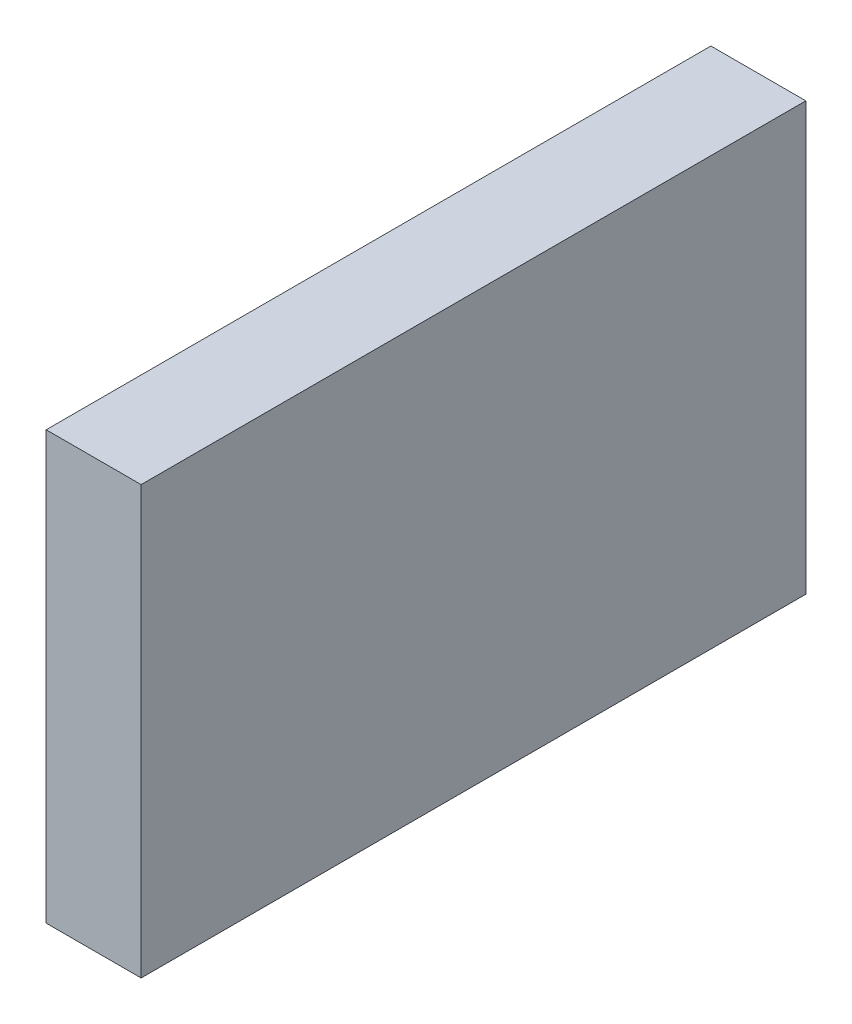
from build123d import *

# Parameters (mm, degrees)
SKETCH1_W           = 7
SKETCH1_H           = 4.5
BOSS_EXTRUDE1_DEPTH = 1


with BuildPart() as part:
    # Sketch1 → Boss-Extrude1 (new body)
    with BuildSketch(Plane(origin=(0, 0, 0), x_dir=(0, 0, -1), z_dir=(1, 0, 0))):
        with Locations((0.481339774, -0.318319493)):
            Rectangle(SKETCH1_W, SKETCH1_H)
    extrude(amount=BOSS_EXTRUDE1_DEPTH)


solid = part.part
